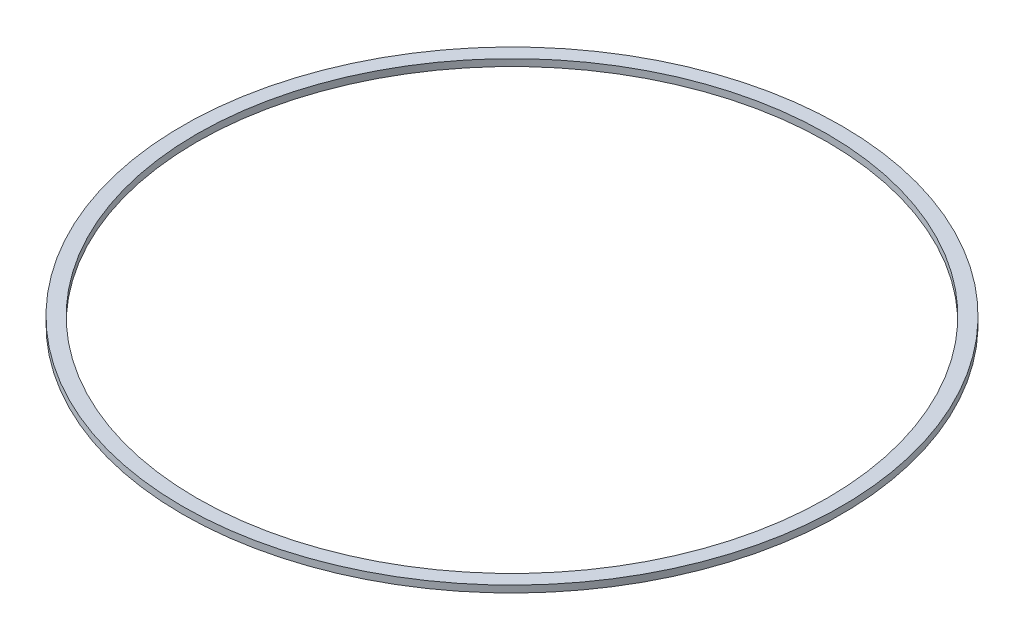
from build123d import *

# Parameters (mm, degrees)
SKETCH4_W = 2.5
SKETCH4_H = 1.2


with BuildPart() as part:
    # Sketch4 → Revolve1 (revolve)
    with BuildSketch(Plane.XY):
        with Locations((-56.45, 8.7)):
            Rectangle(SKETCH4_W, SKETCH4_H)
    revolve(axis=Axis((0, 0, 0), (0, 1, 0)))


solid = part.part
